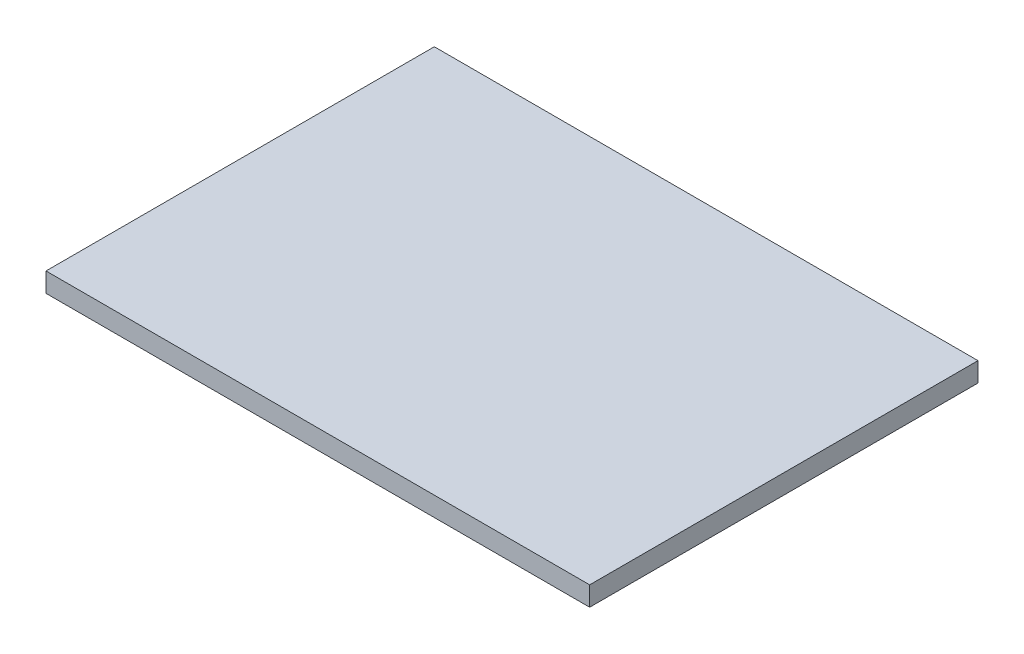
from build123d import *

# Parameters (mm, degrees)
SKETCH1_W           = 711.2
SKETCH1_H           = 508
BOSS_EXTRUDE1_DEPTH = 25.4


with BuildPart() as part:
    # Sketch1 → Boss-Extrude1 (new body)
    with BuildSketch(Plane(origin=(0, 0, 0), x_dir=(1, 0, 0), z_dir=(0, 1, 0))):
        with Locations((179.878427205, -133.748140276)):
            Rectangle(SKETCH1_W, SKETCH1_H)
    extrude(amount=BOSS_EXTRUDE1_DEPTH)


solid = part.part
